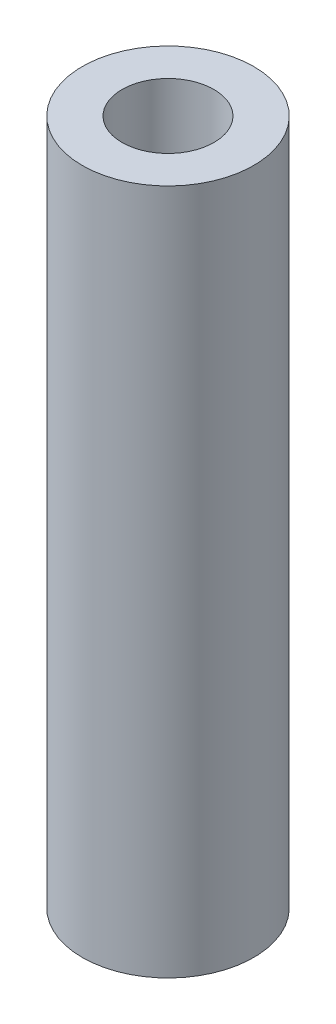
from build123d import *

# Parameters (mm, degrees)
SKETCH1_R      = 3.175
SKETCH1_R_2    = 1.7018
EXTRUDE1_DEPTH = 25.4


with BuildPart() as part:
    # Sketch1 → Extrude1 (new body)
    with BuildSketch(Plane(origin=(0, 0, 0), x_dir=(1, 0, 0), z_dir=(0, 1, 0))):
        Circle(SKETCH1_R)
        Circle(SKETCH1_R_2, mode=Mode.SUBTRACT)
    extrude(amount=EXTRUDE1_DEPTH)


solid = part.part
